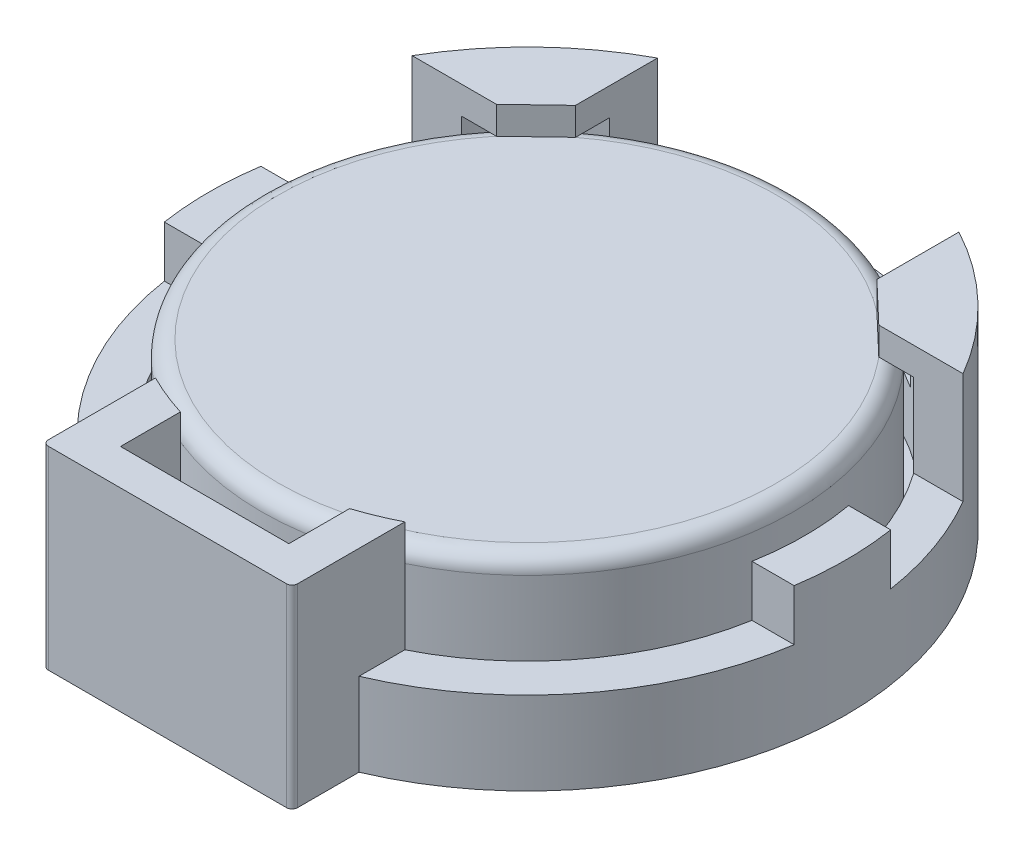
from build123d import *

# Parameters (mm, degrees)
CROQUIS1_R            = 11.5
EXTRUIR1_DEPTH        = 7
CROQUIS2_R            = 10
CORTAR_EXTRUIR1_DEPTH = 6
CROQUIS3_W            = 24.654500354
CROQUIS3_H            = 10.907748641
CORTAR_EXTRUIR2_DEPTH = 4
CROQUIS4_W            = 23.977576975
CROQUIS4_H            = 2.848058902
CORTAR_EXTRUIR3_DEPTH = 4
EXTRUIR2_DEPTH        = 4
EXTRUIR2_DEPTH_BACK   = 3
REDONDEO1_R           = 0.2
CROQUIS6_R            = 9.601083159
EXTRUIR3_DEPTH        = 5
REDONDEO2_R           = 0.6
EXTRUIR5_DEPTH        = 1
EXTRUIR5_2_DEPTH      = 1


with BuildPart() as part:
    # Croquis1 → Extruir1 (new body)
    with BuildSketch(Plane(origin=(0, 0, 0), x_dir=(1, 0, 0), z_dir=(0, 1, 0))):
        Circle(CROQUIS1_R)
    extrude(amount=EXTRUIR1_DEPTH)

    # Croquis2 → Cortar-Extruir1 (cut)
    with BuildSketch(Plane(origin=(0, 7, 0), x_dir=(-1, 0, 0), z_dir=(0, 1, 0))):
        Circle(CROQUIS2_R)
    extrude(amount=-CORTAR_EXTRUIR1_DEPTH, mode=Mode.SUBTRACT)

    # Croquis3 → Cortar-Extruir2 (cut)
    with BuildSketch(Plane(origin=(0, 7, 0), x_dir=(-1, 0, 0), z_dir=(0, 1, 0))):
        Polygon((-12.053311284, -1.7432475), (12.60118907, -1.7432475), (12.60118907, -5.778118356), (5.440306875, -5.778118356), (5.440306875, -12.650996141), (-5.440306875, -12.650996141), (-5.440306875, -5.778118356), (-12.053311284, -5.778118356), align=None)
        with Locations((0.273938893, 7.197121821)):
            Rectangle(CROQUIS3_W, CROQUIS3_H)
    extrude(amount=-CORTAR_EXTRUIR2_DEPTH, mode=Mode.SUBTRACT)

    # Croquis4 → Cortar-Extruir3 (cut)
    with BuildSketch(Plane.XY.offset(1.7432475)):
        with Locations((0.057730923, 6.271084337)):
            Rectangle(CROQUIS4_W, CROQUIS4_H)
    extrude(amount=-CORTAR_EXTRUIR3_DEPTH, mode=Mode.SUBTRACT)

    # Croquis5 → Extruir2 (add, two sides)
    with BuildSketch(Plane(origin=(0, 3, 0), x_dir=(-1, 0, 0), z_dir=(0, 1, 0))) as extruir2_sk:
        with BuildLine():
            Line((-4.5, 8.93028555), (-4.5, 13))
            Line((-4.5, 13), (4.5, 13))
            Line((4.5, 13), (4.5, 8.93028555))
            ThreePointArc((4.5, 8.93028555), (3.756725553, 9.267524649), (2.988424285, 9.543024693))
            Line((2.988424285, 9.543024693), (2.988424285, 11.704661784))
            Line((2.988424285, 11.704661784), (-3.088038428, 11.704661784))
            Line((-3.088038428, 11.704661784), (-3.088038428, 9.51125747))
            ThreePointArc((-3.088038428, 9.51125747), (-3.805123374, 9.247758437), (-4.5, 8.93028555))
        make_face()
    extrude(amount=EXTRUIR2_DEPTH)
    extrude(extruir2_sk.sketch, amount=-EXTRUIR2_DEPTH_BACK)

    # Redondeo1
    redondeo1_edges = [part.edges().sort_by_distance(p)[0] for p in [
        (4.5, 3.5, 13),
        (-4.5, 3.5, 13),
    ]]
    fillet(redondeo1_edges, radius=REDONDEO1_R)


with BuildPart() as body_2:
    # Croquis6 → Extruir3 (new body)
    with BuildSketch(Plane(origin=(0, 1, 0), x_dir=(-1, 0, 0), z_dir=(0, 1, 0))):
        Circle(CROQUIS6_R)
    extrude(amount=EXTRUIR3_DEPTH)

    # Redondeo2
    redondeo2_edges = [body_2.edges().sort_by_distance(p)[0] for p in [
        (9.601083159, 6, 0),
    ]]
    fillet(redondeo2_edges, radius=REDONDEO2_R)


with BuildPart() as body_3:
    # Croquis7 → Extruir5 (new body)
    with BuildSketch(Plane(origin=(0, 7, 0), x_dir=(-1, 0, 0), z_dir=(0, 1, 0))):
        with BuildLine():
            Line((-5.440306875, -8.390653199), (-5.440306875, -7.170952457))
            Line((-5.440306875, -7.170952457), (-6.90165533, -5.778118356))
            Line((-6.90165533, -5.778118356), (-8.161700084, -5.778118356))
            ThreePointArc((-8.161700084, -5.778118356), (-6.925314643, -7.213876704), (-5.440306875, -8.390653199))
        make_face()
    extrude(amount=-EXTRUIR5_DEPTH)


with BuildPart() as body_4:
    # Croquis7 → Extruir5 2 (new body)
    with BuildSketch(Plane(origin=(0, 7, 0), x_dir=(-1, 0, 0), z_dir=(0, 1, 0))):
        with BuildLine():
            Line((6.90165533, -5.778118356), (5.440306875, -7.170952457))
            Line((5.440306875, -7.170952457), (5.440306875, -8.390653199))
            ThreePointArc((5.440306875, -8.390653199), (6.925314643, -7.213876704), (8.161700084, -5.778118356))
            Line((8.161700084, -5.778118356), (6.90165533, -5.778118356))
        make_face()
    extrude(amount=-EXTRUIR5_2_DEPTH)


with BuildPart() as part_1:
    add(part.part)

    # Combinar1: union body 4, body 3
    add(body_4.part)
    add(body_3.part)


solid = Compound([body_2.part, part_1.part])
